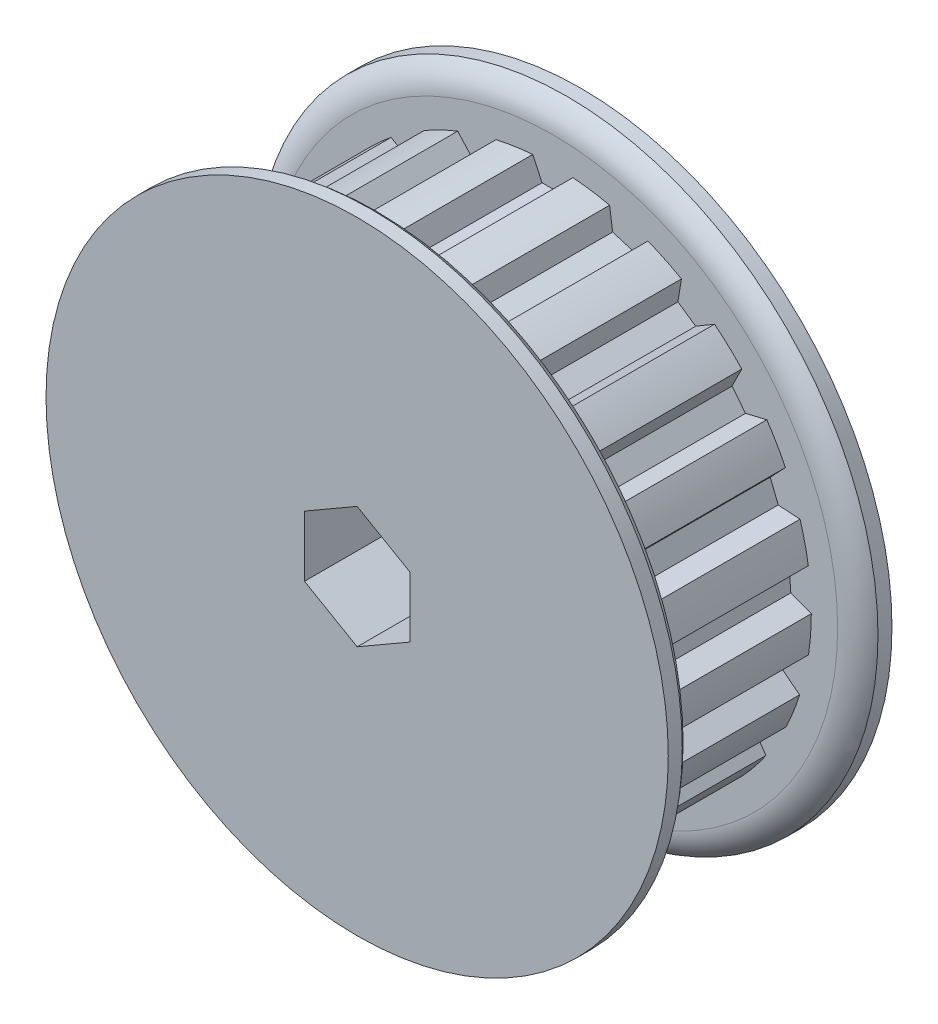
from build123d import *

# Parameters (mm, degrees)
CUT_EXTRUDE1_START = 1.397
CUT_EXTRUDE1_DEPTH = 10.7188
CIRPATTERN1_COUNT  = 21
SKETCH4_R          = 1.5875
CUT_EXTRUDE2_DEPTH = 31.241836167
CUT_EXTRUDE3_DEPTH = 1.190625
CIRPATTERN2_COUNT  = 2
CIRPATTERN2_ANGLE  = 90
CUT_EXTRUDE4_DEPTH = 50.8
SKETCH8_R          = 12.7
CUT_EXTRUDE5_DEPTH = 50.8


with BuildPart() as part:
    # Sketch2 → Revolve1 (revolve)
    with BuildSketch(Plane(origin=(0, 0, 0), x_dir=(0, 0, -1), z_dir=(1, 0, 0)), mode=Mode.PRIVATE) as revolve1_sk:
        with BuildLine():
            Line((-11.1125, 3.175), (11.1125, 3.175))
            Line((11.1125, 3.175), (11.1125, 19.8882))
            Line((11.1125, 19.8882), (10.21715, 19.8882))
            ThreePointArc((10.21715, 19.8882), (9.559562343, 19.158250378), (9.3218, 18.204983865))
            Line((9.3218, 18.204983865), (9.3218, 16.521767729))
            Line((9.3218, 16.521767729), (-1.397, 16.521767729))
            Line((-1.397, 16.521767729), (-1.397, 18.204983865))
            ThreePointArc((-1.397, 18.204983865), (-1.634762343, 19.158250378), (-2.29235, 19.8882))
            Line((-2.29235, 19.8882), (-3.1877, 19.8882))
            Line((-3.1877, 19.8882), (-3.1877, 11.9126))
            Line((-3.1877, 11.9126), (-11.1125, 11.9126))
            Line((-11.1125, 11.9126), (-11.1125, 3.175))
        make_face()
    revolve(revolve1_sk.sketch.rotate(Axis((0, 0, 11.1125), (0, 0, -1)), 90), axis=Axis((0, 0, 11.1125), (0, 0, -1)))

    # Sketch3 → Cut-Extrude1 (cut)
    with BuildSketch(Plane.XY.offset(CUT_EXTRUDE1_START)):
        with BuildLine():
            Line((-0.690489274, 15.2019), (0.690489274, 15.2019))
            Line((0.690489274, 15.2019), (1.2827, 16.4719))
            ThreePointArc((1.2827, 16.4719), (0, 16.521767729), (-1.2827, 16.4719))
            Line((-1.2827, 16.4719), (-0.690489274, 15.2019))
        make_face()
    cut_extrude1 = extrude(amount=-CUT_EXTRUDE1_DEPTH, mode=Mode.SUBTRACT)

    # CirPattern1: Cut-Extrude1 ×21 about axis
    cirpattern1_axis = Axis((0, 0, 0), (0, 0, 1))
    for i in range(1, CIRPATTERN1_COUNT):
        add(cut_extrude1.rotate(cirpattern1_axis, i * 360 / CIRPATTERN1_COUNT), mode=Mode.SUBTRACT)

    # Sketch4 → Cut-Extrude2 (cut, through all)
    with BuildSketch(Plane(origin=(0, 0, 0), x_dir=(1, 0, 0), z_dir=(0, 1, 0))):
        with Locations(Location((0, -7.1501, 0), (0, 0, 90))):
            Circle(SKETCH4_R)
    cut_extrude2 = extrude(amount=CUT_EXTRUDE2_DEPTH, mode=Mode.SUBTRACT)

    # Sketch5 → Revolve2 (revolve)
    with BuildSketch(Plane.XY.offset(7.1501), mode=Mode.PRIVATE) as revolve2_sk:
        Polygon((1.0795, 11.806349246), (1.5875, 11.298349246), (1.5875, 3.81), (0.9525, 3.175), (0, 3.175), (0, 11.806349246), align=None)
    revolve2 = revolve(revolve2_sk.sketch.rotate(Axis((0, 0, 7.1501), (0, 1, 0)), 90), axis=Axis((0, 0, 7.1501), (0, 1, 0)))

    # Sketch6 → Cut-Extrude3 (cut)
    with BuildSketch(Plane(origin=(0, 11.806349246, 0), x_dir=(1, 0, 0), z_dir=(0, 1, 0))):
        Polygon((0, -6.233556448), (-0.79375, -6.691828224), (-0.79375, -7.608371776), (0, -8.066643552), (0.79375, -7.608371776), (0.79375, -6.691828224), align=None)
    cut_extrude3 = extrude(amount=-CUT_EXTRUDE3_DEPTH, mode=Mode.SUBTRACT)

    # CirPattern2: Cut-Extrude2, Revolve2, Cut-Extrude3 ×2 about axis
    cirpattern2_axis = Axis((0, 0, 0), (0, 0, -1))
    add([cut_extrude2.rotate(cirpattern2_axis, i * CIRPATTERN2_ANGLE / (CIRPATTERN2_COUNT - 1)) for i in range(1, CIRPATTERN2_COUNT)], mode=Mode.SUBTRACT)
    add([revolve2.rotate(cirpattern2_axis, i * CIRPATTERN2_ANGLE / (CIRPATTERN2_COUNT - 1)) for i in range(1, CIRPATTERN2_COUNT)])
    add([cut_extrude3.rotate(cirpattern2_axis, i * CIRPATTERN2_ANGLE / (CIRPATTERN2_COUNT - 1)) for i in range(1, CIRPATTERN2_COUNT)], mode=Mode.SUBTRACT)

    # Sketch7 → Cut-Extrude4 (cut)
    with BuildSketch(Plane.XY.offset(11.1125)):
        Polygon((0, 3.886144662), (-3.3655, 1.943072331), (-3.3655, -1.943072331), (0, -3.886144662), (3.3655, -1.943072331), (3.3655, 1.943072331), align=None)
    extrude(amount=-CUT_EXTRUDE4_DEPTH, mode=Mode.SUBTRACT)

    # Sketch8 → Cut-Extrude5 (cut)
    with BuildSketch(Plane.XY.offset(3.1877)):
        Circle(SKETCH8_R)
    extrude(amount=CUT_EXTRUDE5_DEPTH, mode=Mode.SUBTRACT)


solid = part.part
